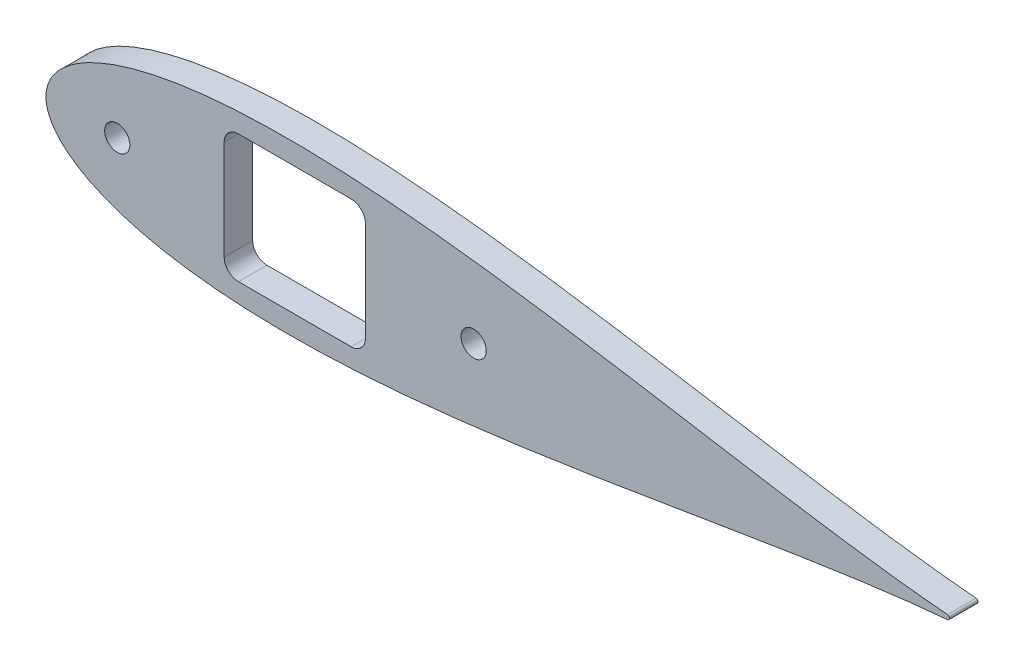
from build123d import *

# Parameters (mm, degrees)
BOSS_EXTRUDE1_DEPTH   = 5.4737
SCALE1_SCALE          = 0.25
BOSS_EXTRUDE2_DEPTH   = 5.08
SKETCH10_W            = 25.167167629
SKETCH10_H            = 22.8092
CUT_EXTRUDE6_DEPTH    = 6.0800001
FILLET1_R             = 2.54
F_8_CLEARANCE_HOLE1_D = 4.4958


with BuildPart() as part:
    # Sketch2 → Boss-Extrude1 (new body)
    with BuildSketch(Plane.XY):
        with BuildLine():
            add(Edge.make_bspline(
                [(642.510849283, 1.582039112), (641.993392355, 1.625070631), (638.093728429, 1.953546407), (630.413817462, 2.663385493), (619.014124193, 3.849253664), (606.374988512, 5.304428983), (592.543922516, 7.037634907), (577.585454095, 9.050636147), (561.564270734, 11.338919625), (544.549749946, 13.890665375), (526.614143658, 16.687720753), (507.832591566, 19.705111663), (488.282710288, 22.911672601), (468.044367735, 26.27043606), (447.199424328, 29.739007432), (425.831595832, 33.270324121), (404.02631566, 36.813220545), (381.870662856, 40.313266856), (359.453314895, 43.713502532), (336.86454415, 46.955447457), (314.196207315, 49.979843895), (291.541767704, 52.727712704), (268.996310773, 55.141201012), (246.65655865, 57.164603829), (224.620860897, 58.745176641), (202.989192599, 59.8341217), (181.863132616, 60.387506142), (161.345829027, 60.366961324), (141.542033828, 59.739895824), (122.558104573, 58.481758104), (104.502313427, 56.574303932), (87.485018636, 54.008935199), (71.619696083, 50.784752003), (57.023709725, 46.912543066), (43.82045433, 42.41500246), (32.141645239, 37.332204029), (22.129107375, 31.731455339), (13.932423524, 25.726412106), (7.689616489, 19.513207632), (3.463136343, 13.420354421), (1.106333228, 7.923389435), (0.154611582, 3.513796615), (-0.062151598, 0), (0.154611582, -3.513796615), (1.106333228, -7.923389435), (3.463136343, -13.420354421), (7.689616489, -19.513207632), (13.932423524, -25.726412106), (22.129107375, -31.731455339), (32.141645239, -37.332204029), (43.82045433, -42.41500246), (57.023709725, -46.912543066), (71.619696083, -50.784752003), (87.485018636, -54.008935199), (104.502313427, -56.574303932), (122.558104573, -58.481758104), (141.542033828, -59.739895824), (161.345829027, -60.366961324), (181.863132616, -60.387506142), (202.989192599, -59.8341217), (224.620860897, -58.745176641), (246.65655865, -57.164603829), (268.996310773, -55.141201012), (291.541767704, -52.727712704), (314.196207315, -49.979843895), (336.86454415, -46.955447457), (359.453314895, -43.713502532), (381.870662856, -40.313266856), (404.02631566, -36.813220545), (425.831595832, -33.270324121), (447.199424328, -29.739007432), (468.044367735, -26.27043606), (488.282710288, -22.911672601), (507.832591566, -19.705111663), (526.614143658, -16.687720753), (544.549749946, -13.890665375), (561.564270734, -11.338919625), (577.585454095, -9.050636147), (592.543922516, -7.037634907), (606.374988512, -5.304428983), (619.014124193, -3.849253664), (630.413817462, -2.663385493), (638.093728429, -1.953546407), (641.993392355, -1.625070631), (642.510849283, -1.582039112)],
                knots=[0.020157042, 0.020157042, 0.020157042, 0.020157042, 0.021270888, 0.028552555, 0.036780684, 0.045920102, 0.055931764, 0.066772884, 0.07839713, 0.090754827, 0.103793165, 0.117456432, 0.131686226, 0.146421738, 0.161599998, 0.177156133, 0.193023668, 0.209134786, 0.225420633, 0.241811602, 0.258237647, 0.274628557, 0.290914287, 0.307025229, 0.322892517, 0.338448342, 0.353626207, 0.368361232, 0.382590428, 0.396252961, 0.409290412, 0.42164701, 0.433269881, 0.444109249, 0.45411864, 0.463255055, 0.471479114, 0.478755289, 0.485052318, 0.490344026, 0.494609833, 0.497833231, 0.5, 0.502166769, 0.505390167, 0.509655974, 0.514947682, 0.521244711, 0.528520886, 0.536744945, 0.54588136, 0.555890751, 0.566730119, 0.57835299, 0.590709588, 0.603747039, 0.617409572, 0.631638768, 0.646373793, 0.661551658, 0.677107483, 0.692974771, 0.709085713, 0.725371443, 0.741762353, 0.758188398, 0.774579367, 0.790865214, 0.806976332, 0.822843867, 0.838400002, 0.853578262, 0.868313774, 0.882543568, 0.896206835, 0.909245173, 0.92160287, 0.933227116, 0.944068236, 0.954079898, 0.963219316, 0.971447445, 0.978729112, 0.979842958, 0.979842958, 0.979842958, 0.979842958], degree=3))
            ThreePointArc((642.510849283, -1.582039112), (643.966787522, 0), (642.510849283, 1.582039112))
        make_face()
    extrude(amount=BOSS_EXTRUDE1_DEPTH)


with BuildPart() as part_1:
    # Scale1: scaled about (0, 0, 0)
    add(part.part.scale(SCALE1_SCALE))

    # Sketch11 → Boss-Extrude2 (add)
    with BuildSketch(Plane(origin=(0, 0, 0), x_dir=(-1, 0, 0), z_dir=(0, 0, -1))):
        with BuildLine():
            ThreePointArc((-160.627712321, 0.395509778), (-160.99169688, 0), (-160.627712321, -0.395509778))
            add(Edge.make_bspline(
                [(-160.627712321, -0.395509778), (-160.498348089, -0.406267658), (-159.523432107, -0.488386602), (-157.603454365, -0.665846373), (-154.753531048, -0.962313416), (-151.593747128, -1.326107246), (-148.135980629, -1.759408727), (-144.396363524, -2.262659037), (-140.391067684, -2.834729906), (-136.137437486, -3.472666344), (-131.653535914, -4.171930188), (-126.958147892, -4.926277916), (-122.070677572, -5.72791815), (-117.011091934, -6.567609015), (-111.799856082, -7.434751858), (-106.457898958, -8.31758103), (-101.006578915, -9.203305136), (-95.467665714, -10.078316714), (-89.863328724, -10.928375633), (-84.216136038, -11.738861864), (-78.549051829, -12.494960974), (-72.885441926, -13.181928176), (-67.249077693, -13.785300253), (-61.664139662, -14.291150957), (-56.155215224, -14.68629416), (-50.74729815, -14.958530425), (-45.465783154, -15.096876536), (-40.336457257, -15.091740331), (-35.385508457, -14.934973956), (-30.639526143, -14.620439526), (-26.125578357, -14.143575983), (-21.871254659, -13.5022338), (-17.904924021, -12.696188001), (-14.255927431, -11.728135766), (-10.955113583, -10.603750615), (-8.03541131, -9.333051007), (-5.532276844, -7.932863835), (-3.483105881, -6.431603026), (-1.922404122, -4.878301908), (-0.865784086, -3.355088605), (-0.276583307, -1.980847359), (-0.038652895, -0.878449154), (0.015537899, 0), (-0.038652895, 0.878449154), (-0.276583307, 1.980847359), (-0.865784086, 3.355088605), (-1.922404122, 4.878301908), (-3.483105881, 6.431603026), (-5.532276844, 7.932863835), (-8.03541131, 9.333051007), (-10.955113583, 10.603750615), (-14.255927431, 11.728135766), (-17.904924021, 12.696188001), (-21.871254659, 13.5022338), (-26.125578357, 14.143575983), (-30.639526143, 14.620439526), (-35.385508457, 14.934973956), (-40.336457257, 15.091740331), (-45.465783154, 15.096876536), (-50.74729815, 14.958530425), (-56.155215224, 14.68629416), (-61.664139662, 14.291150957), (-67.249077693, 13.785300253), (-72.885441926, 13.181928176), (-78.549051829, 12.494960974), (-84.216136038, 11.738861864), (-89.863328724, 10.928375633), (-95.467665714, 10.078316714), (-101.006578915, 9.203305136), (-106.457898958, 8.31758103), (-111.799856082, 7.434751858), (-117.011091934, 6.567609015), (-122.070677572, 5.72791815), (-126.958147892, 4.926277916), (-131.653535914, 4.171930188), (-136.137437486, 3.472666344), (-140.391067684, 2.834729906), (-144.396363524, 2.262659037), (-148.135980629, 1.759408727), (-151.593747128, 1.326107246), (-154.753531048, 0.962313416), (-157.603454365, 0.665846373), (-159.523432107, 0.488386602), (-160.498348089, 0.406267658), (-160.627712321, 0.395509778)],
                knots=[0.020157042, 0.020157042, 0.020157042, 0.020157042, 0.021270888, 0.028552555, 0.036780684, 0.045920102, 0.055931764, 0.066772884, 0.07839713, 0.090754827, 0.103793165, 0.117456432, 0.131686226, 0.146421738, 0.161599998, 0.177156133, 0.193023668, 0.209134786, 0.225420633, 0.241811602, 0.258237647, 0.274628557, 0.290914287, 0.307025229, 0.322892517, 0.338448342, 0.353626207, 0.368361232, 0.382590428, 0.396252961, 0.409290412, 0.42164701, 0.433269881, 0.444109249, 0.45411864, 0.463255055, 0.471479114, 0.478755289, 0.485052318, 0.490344026, 0.494609833, 0.497833231, 0.5, 0.502166769, 0.505390167, 0.509655974, 0.514947682, 0.521244711, 0.528520886, 0.536744945, 0.54588136, 0.555890751, 0.566730119, 0.57835299, 0.590709588, 0.603747039, 0.617409572, 0.631638768, 0.646373793, 0.661551658, 0.677107483, 0.692974771, 0.709085713, 0.725371443, 0.741762353, 0.758188398, 0.774579367, 0.790865214, 0.806976332, 0.822843867, 0.838400002, 0.853578262, 0.868313774, 0.882543568, 0.896206835, 0.909245173, 0.92160287, 0.933227116, 0.944068236, 0.954079898, 0.963219316, 0.971447445, 0.978729112, 0.979842958, 0.979842958, 0.979842958, 0.979842958], degree=3))
        make_face()
    extrude(amount=-BOSS_EXTRUDE2_DEPTH)

    # Sketch10 → Cut-Extrude6 (cut, through all)
    with BuildSketch(Plane.XY):
        with Locations((44.333583815, 0)):
            Rectangle(SKETCH10_W, SKETCH10_H)
    extrude(amount=CUT_EXTRUDE6_DEPTH, mode=Mode.SUBTRACT)

    # Fillet1
    fillet1_edges = [part_1.edges().sort_by_distance(p)[0] for p in [
        (56.917167629, -11.4046, 2.54),
        (56.917167629, 11.4046, 2.54),
        (31.75, 11.4046, 2.54),
        (31.75, -11.4046, 2.54),
    ]]
    fillet(fillet1_edges, radius=FILLET1_R)

    # #8 Clearance Hole1 (through all)
    with Locations(Plane.XY.offset(5.08)):
        with Locations((12.7, 0), (76.2, 0)):
            Hole(F_8_CLEARANCE_HOLE1_D / 2)


solid = part_1.part
